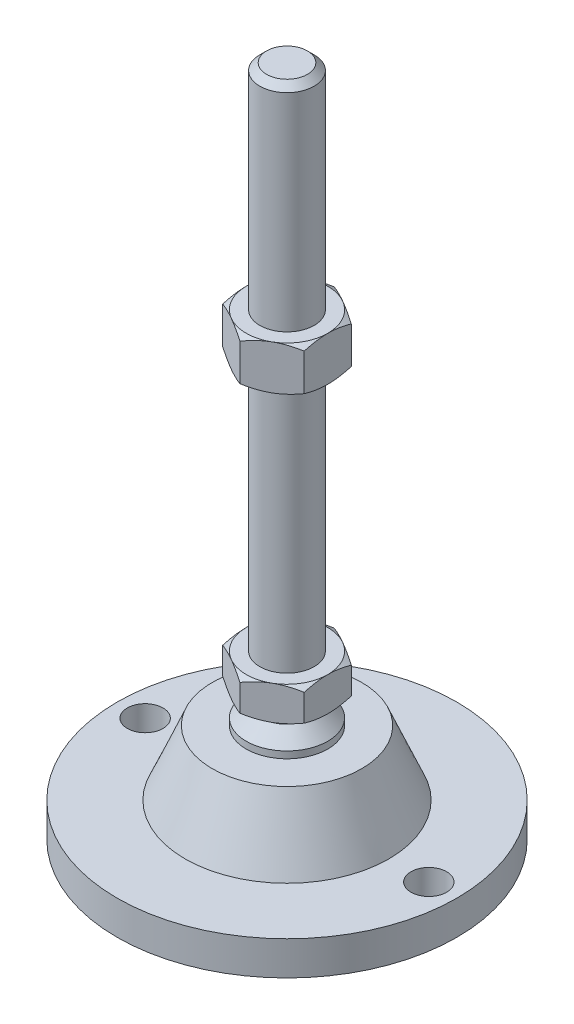
from build123d import *

# Parameters (mm, degrees)
EXTRUDE_1_DEPTH     = 10
EXTRUDE_2_DEPTH     = 13
SKETCH_5_R          = 5.25
CUT_EXTRUDE_1_DEPTH = 11


with BuildPart() as part:
    # Эскиз1 → Повернуть1 (revolve)
    with BuildSketch(Plane.XY, mode=Mode.PRIVATE) as revolve_1_sk:
        Polygon((0, 0), (-50, 0), (-50, 10), (-30, 10), (-22, 29), (-12, 29), (-12, 31), (-8, 35), (-8, 38), (-8, 48), (-8, 196), (-6, 198), (0, 198), align=None)
    revolve(revolve_1_sk.sketch.rotate(Axis((0, 0, 0), (0, 1, 0)), 180), axis=Axis((0, 0, 0), (0, 1, 0)))  # turned: the seam where the file's is

    # Эскиз2 → Бобышка-Вытянуть1 (add)
    with BuildSketch(Plane(origin=(0, 38, 0), x_dir=(1, 0, 0), z_dir=(0, 1, 0))):
        Polygon((0, 13.856406461), (-12, 6.92820323), (-12, -6.92820323), (0, -13.856406461), (12, -6.92820323), (12, 6.92820323), align=None)
    extrude(amount=EXTRUDE_1_DEPTH)

    # Эскиз3 → Бобышка-Вытянуть2 (add)
    with BuildSketch(Plane(origin=(0, 122, 0), x_dir=(1, 0, 0), z_dir=(0, 1, 0))):
        Polygon((12, 6.92820323), (0, 13.856406461), (-12, 6.92820323), (-12, -6.92820323), (0, -13.856406461), (12, -6.92820323), align=None)
    extrude(amount=EXTRUDE_2_DEPTH)

    # Эскиз4 → Вырез-Повернуть2 (revolve, cut)
    with BuildSketch(Plane.XY, mode=Mode.PRIVATE) as cut_revolve_2_sk:
        Polygon((-23.258330249, 135), (-12, 135), (-23.258330249, 128.5), align=None)
        Polygon((-23.258330249, 122), (-23.258330249, 128.5), (-12, 122), align=None)
        Polygon((-20.660254038, 48), (-20.660254038, 43), (-12, 48), align=None)
        Polygon((-20.660254038, 43), (-20.660254038, 38), (-12, 38), align=None)
    revolve(cut_revolve_2_sk.sketch.rotate(Axis((0, 198, 0), (0, -1, 0)), 180), axis=Axis((0, 198, 0), (0, -1, 0)), mode=Mode.SUBTRACT)  # turned: the seam where the file's is

    # Эскиз5 → Вырез-Вытянуть1 (cut, through all)
    with BuildSketch(Plane(origin=(0, 10, 0), x_dir=(1, 0, 0), z_dir=(0, 1, 0))):
        with Locations(Location((-41.75, 0, 0), (0, 0, 180))):  # turned: the seam where the file's is
            Circle(SKETCH_5_R)
        with Locations(Location((41.75, 0, 0), (0, 0, 180))):  # turned: the seam where the file's is
            Circle(SKETCH_5_R)
    extrude(amount=-CUT_EXTRUDE_1_DEPTH, mode=Mode.SUBTRACT)


solid = part.part
